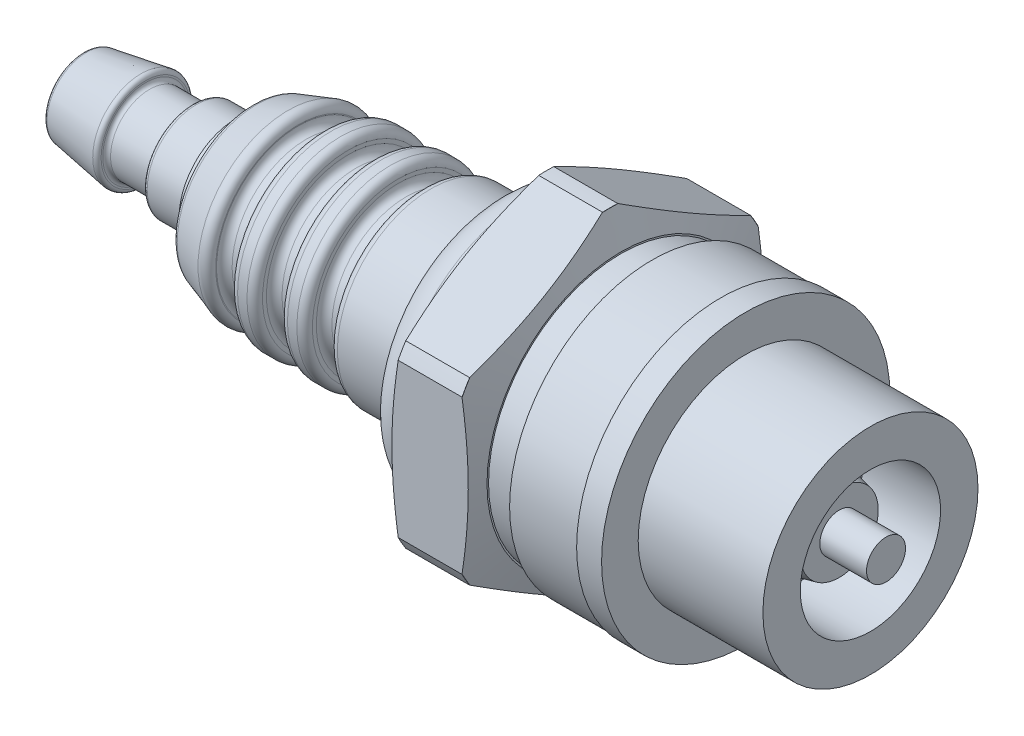
from build123d import *

# Parameters (mm, degrees)
SKETCH2_R          = 12.626586576
CUT_EXTRUDE1_DEPTH = 10
SKETCH3_W          = 1.6
SKETCH3_H          = 2.464975845
SKETCH3_H_2        = 2.36352657
FILLET1_R          = 0.5
FILLET2_R          = 0.25
FILLET3_R          = 2


with BuildPart() as part:
    # Sketch1 → Revolve1 (revolve)
    with BuildSketch(Plane.XY):
        Polygon((2, 0), (2, 1.65), (0, 1.65), (0, 2.5), (4, 3.15), (4, 2.5), (7, 2.5), (7, 3.15), (9.8, 3.15), (9.8, 3.65), (10.8, 3.65), (10.8, 5), (13.8, 6), (26.5, 6), (26.5, 8.6), (29, 8.6), (29, 10.7), (34.5, 10.7), (34.5, 8.5), (36.5, 8.5), (36.5, 9.15), (40.9, 9.15), (40.9, 9.25), (42.5, 9.25), (42.5, 6.9), (50.5, 6.9), (50.5, 4.5), (45.5, 4.5), (45.5, 3.15), (48.5, 2.5), (48.5, 1.25), (51.5, 1.25), (51.5, 0), align=None)
    revolve(axis=Axis((0, 0, 0), (1, 0, 0)))

    # Sketch2 → Cut-Extrude1 (cut)
    with BuildSketch(Plane(origin=(34.5, 0, 0), x_dir=(0, 0, -1), z_dir=(1, 0, 0))):
        Circle(SKETCH2_R)
        Polygon((0, 10.969655115), (-9.5, 5.484827557), (-9.5, -5.484827557), (0, -10.969655115), (9.5, -5.484827557), (9.5, 5.484827557), align=None, mode=Mode.SUBTRACT)
    extrude(amount=-CUT_EXTRUDE1_DEPTH, mode=Mode.SUBTRACT)

    # Sketch3 → Cut-Revolve1 (revolve, cut)
    with BuildSketch(Plane.XY):
        with Locations((14.6, 5.982487923)):
            Rectangle(SKETCH3_W, SKETCH3_H)
        with Locations((17.8, 5.931763285)):
            Rectangle(SKETCH3_W, SKETCH3_H_2)
        with Locations((21, 5.931763285)):
            Rectangle(SKETCH3_W, SKETCH3_H_2)
        Polygon((29, 10.688948061), (29, 8.6), (29.7, 10.688948061), (29.7, 11.924429979), (29, 11.924429979), align=None)
        Polygon((34.5, 8.6), (33.8, 10.688948061), (33.8, 13.16419264), (34.5, 13.16419264), (34.5, 10.688948061), align=None)
    revolve(axis=Axis((0, 0, 0), (1, 0, 0)), mode=Mode.SUBTRACT)

    # Fillet1
    fillet1_edges = [part.edges().sort_by_distance(p)[0] for p in [
        (15.4, -4.75, 0),
        (13.8, -6, 0),
        (15.4, -6, 0),
        (13.8, -4.75, 0),
        (18.6, -4.75, 0),
        (17, -6, 0),
        (18.6, -6, 0),
        (17, -4.75, 0),
        (21.8, -4.75, 0),
        (20.2, -6, 0),
        (21.8, -6, 0),
        (20.2, -4.75, 0),
        (10.8, -5, 0),
    ]]
    fillet(fillet1_edges, radius=FILLET1_R)

    # Fillet2
    fillet2_edges = [part.edges().sort_by_distance(p)[0] for p in [
        (7, -3.15, 0),
        (7, -2.5, 0),
        (4, -2.5, 0),
        (4, -3.15, 0),
        (0, -2.5, 0),
    ]]
    fillet(fillet2_edges, radius=FILLET2_R)

    # Fillet3
    fillet3_edges = [part.edges().sort_by_distance(p)[0] for p in [
        (26.5, -8.6, 0),
    ]]
    fillet(fillet3_edges, radius=FILLET3_R)


solid = part.part
